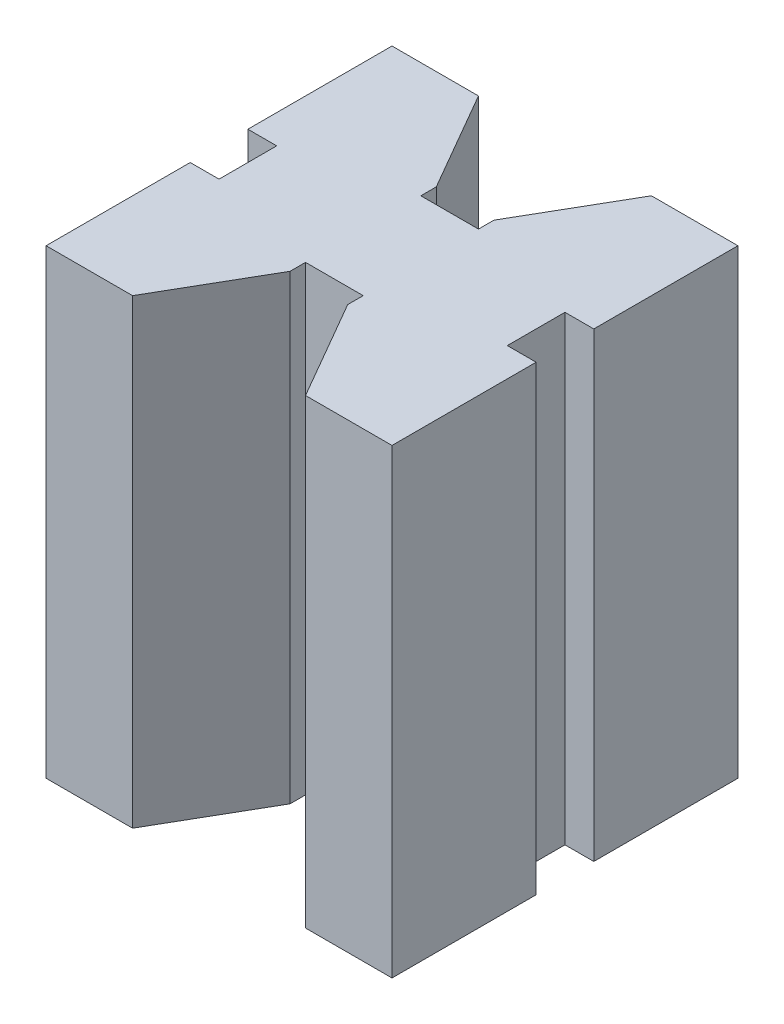
from build123d import *

# Parameters (mm, degrees)
BOSS_EXTRUDE1_DEPTH = 40


with BuildPart() as part:
    # Sketch1 → Boss-Extrude1 (new body)
    with BuildSketch(Plane(origin=(0, 0, 0), x_dir=(1, 0, 0), z_dir=(0, 1, 0))):
        Polygon((-30, 17.5), (-27.5, 17.5), (-27.5, 12.5), (-30, 12.5), (-30, 0), (-22.5, 0), (-17.5, 8.660254038), (-17.5, 10), (-12.5, 10), (-12.5, 8.660254038), (-7.5, 0), (0, 0), (0, 12.5), (-2.5, 12.5), (-2.5, 17.5), (0, 17.5), (0, 30), (-7.5, 30), (-12.5, 21.339745962), (-12.5, 20), (-17.5, 20), (-17.5, 21.339745962), (-22.5, 30), (-30, 30), align=None)
    extrude(amount=BOSS_EXTRUDE1_DEPTH)


solid = part.part
